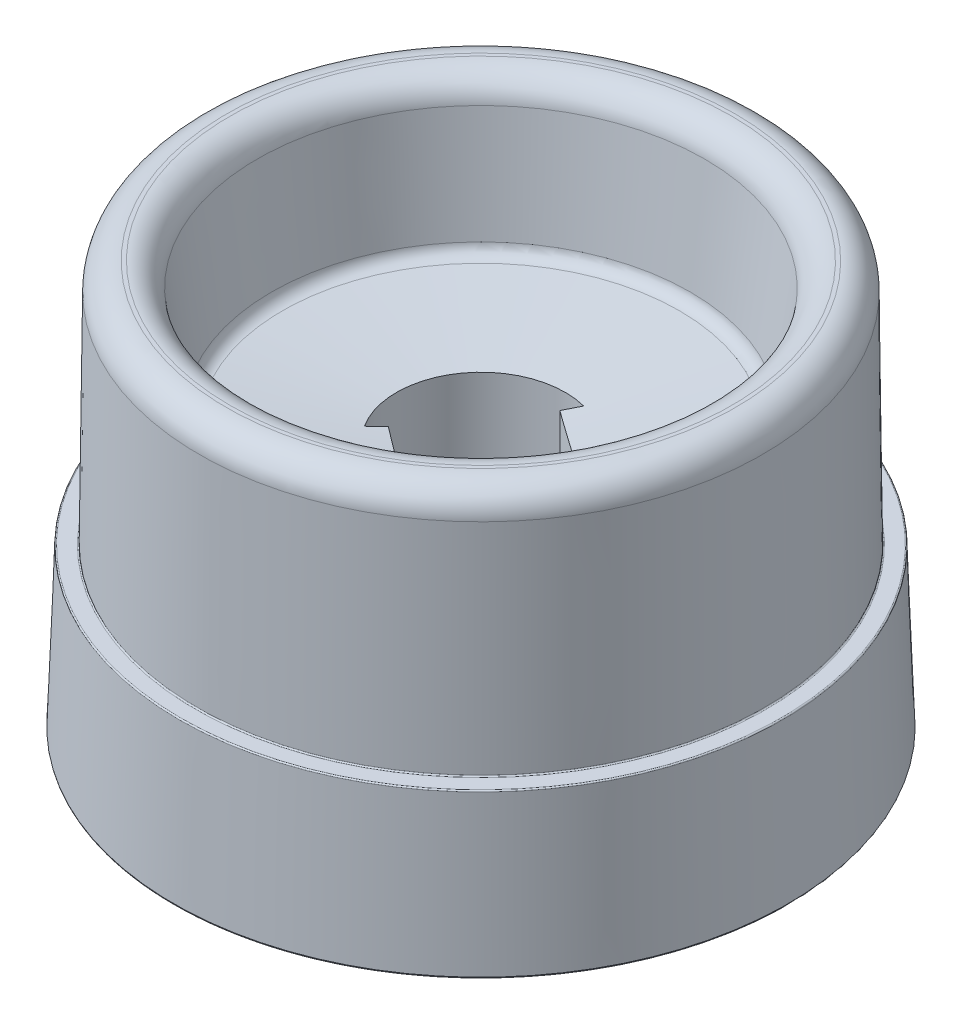
from build123d import *

# Parameters (mm, degrees)
WYTNIJ_WYCI_GNI_CIE1_DEPTH = 10


with BuildPart() as part:
    # Szkic1 → Obrót3 (revolve)
    with BuildSketch(Plane.XY):
        with BuildLine():
            Line((9.779056689, 0), (12.228156189, 0))
            ThreePointArc((12.228156189, 0), (12.264145714, 0.015290432), (12.278123423, 0.051809837))
            Line((12.278123423, 0.051809837), (12.05174547, 6.301809837))
            ThreePointArc((12.05174547, 6.301809837), (12.036487804, 6.335989525), (12.001778236, 6.35))
            Line((12.001778236, 6.35), (11.409443619, 6.35))
            ThreePointArc((11.409443619, 6.35), (11.374286641, 6.364447406), (11.359446749, 6.399440523))
            Line((11.359446749, 6.399440523), (11.262060872, 15.102196591))
            ThreePointArc((11.262060872, 15.102196591), (10.938551226, 15.865046542), (10.172129112, 16.18))
            Line((10.172129112, 16.18), (10.025009987, 16.18))
            ThreePointArc((10.025009987, 16.18), (9.306703371, 15.909838768), (8.944467581, 15.233276341))
            Line((8.944467581, 15.233276341), (8.371803155, 10.91443213))
            ThreePointArc((8.371803155, 10.91443213), (8.22752792, 10.624448061), (7.935802364, 10.483727402))
            Line((7.935802364, 10.483727402), (0, 9.53))
            Line((0, 9.53), (0, 4.2))
            Line((0, 4.2), (9.159433115, 4.2))
            ThreePointArc((9.159433115, 4.2), (9.509603758, 4.056904078), (9.659342437, 3.709522082))
            Line((9.659342437, 3.709522082), (9.729065756, 0.049047792))
            ThreePointArc((9.729065756, 0.049047792), (9.744039624, 0.014309592), (9.779056689, 0))
        make_face()
    revolve(axis=Axis((0, 4.2, 0), (0, 1, 0)))

    # Szkic2 → Wytnij-wyciągnięcie1 (cut)
    with BuildSketch(Plane.XZ.offset(-4.2)):
        with BuildLine():
            Line((2.40580614, -1.327330925), (2.799576276, -1.885163876))
            ThreePointArc((2.799576276, -1.885163876), (2.733226439, 1.980137217), (-0.918959563, 3.247611967))
            Line((-0.918959563, 3.247611967), (-0.511598076, 2.699625525))
            Line((-0.511598076, 2.699625525), (-2.437702254, 1.267800572))
            Line((-2.437702254, 1.267800572), (-2.84506374, 1.815787013))
            ThreePointArc((-2.84506374, 1.815787013), (-2.733226439, -1.980137217), (0.838862844, -3.269216924))
            Line((0.838862844, -3.269216924), (0.445092708, -2.711383973))
            Line((0.445092708, -2.711383973), (2.40580614, -1.327330925))
        make_face()
    extrude(amount=-WYTNIJ_WYCI_GNI_CIE1_DEPTH, mode=Mode.SUBTRACT)


solid = part.part
